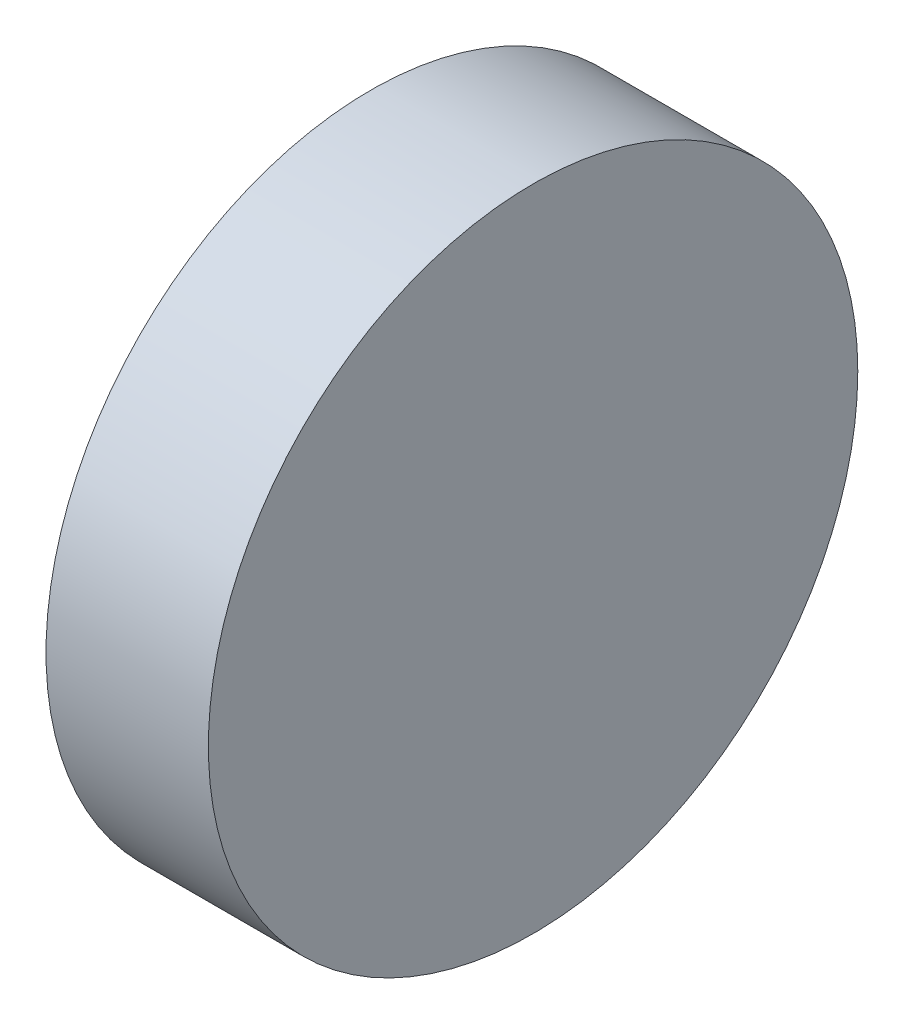
from build123d import *

# Parameters (mm, degrees)
SKETCH2_R           = 20
BOSS_EXTRUDE1_DEPTH = 10


with BuildPart() as part:
    # Sketch2 → Boss-Extrude1 (new body)
    with BuildSketch(Plane(origin=(0, 0, 0), x_dir=(0, 0, -1), z_dir=(1, 0, 0))):
        Circle(SKETCH2_R)
    extrude(amount=BOSS_EXTRUDE1_DEPTH)


solid = part.part
